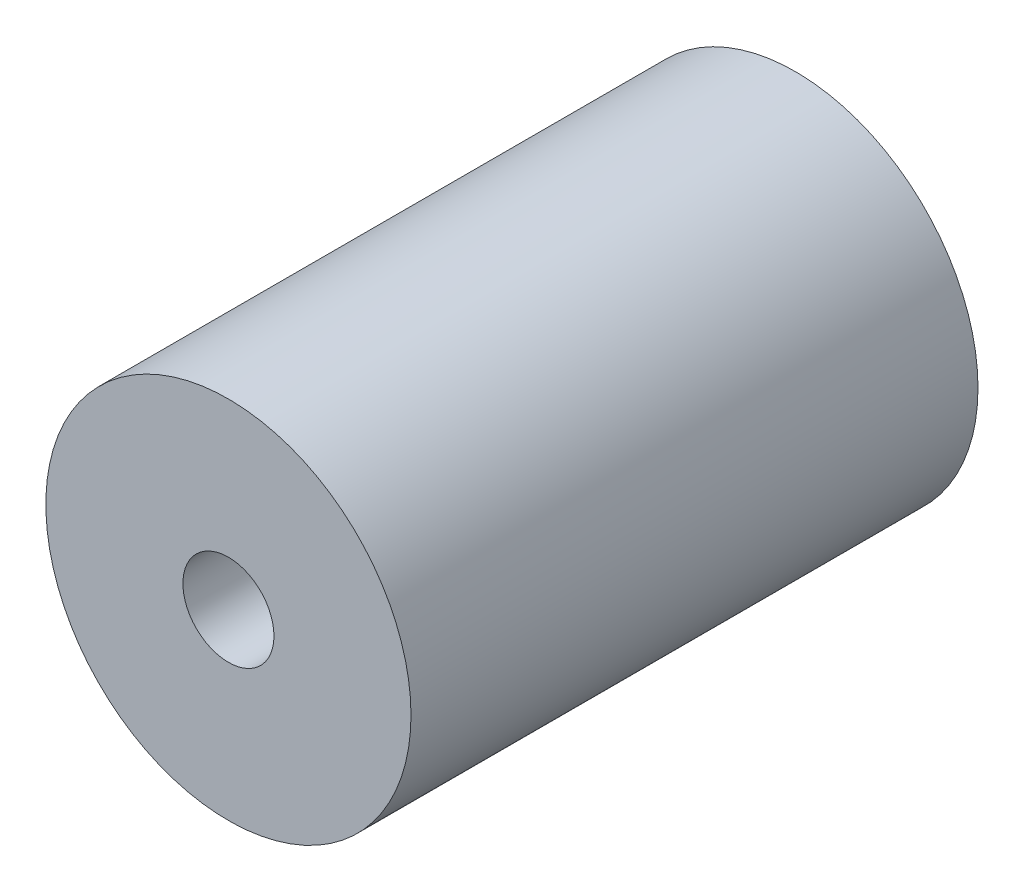
from build123d import *

# Parameters (mm, degrees)
SKETCH1_R                   = 6.1341
BOSS_EXTRUDE1_DEPTH         = 19.05
SKETCH2_R                   = 1.53
CUT_EXTRUDE1_DEPTH          = 20.05
F_1_4_20_TAPPED_HOLE1_D     = 5.1054
F_1_4_20_TAPPED_HOLE1_DEPTH = 9.525
F_1_4_20_TAPPED_HOLE1_TIP   = 1.533816902


with BuildPart() as part:
    # Sketch1 → Boss-Extrude1 (new body)
    with BuildSketch(Plane.XY):
        Circle(SKETCH1_R)
    extrude(amount=BOSS_EXTRUDE1_DEPTH)

    # Sketch2 → Cut-Extrude1 (cut, through all)
    with BuildSketch(Plane.XY.offset(19.05)):
        Circle(SKETCH2_R)
    extrude(amount=-CUT_EXTRUDE1_DEPTH, mode=Mode.SUBTRACT)

    # 1/4-20 Tapped Hole1
    with Locations(Plane(origin=(0, 0, 0), x_dir=(-1, 0, 0), z_dir=(0, 0, -1))):
        with Locations((0, 0)):
            Hole(F_1_4_20_TAPPED_HOLE1_D / 2, depth=F_1_4_20_TAPPED_HOLE1_DEPTH)
            with Locations((0, 0, -(F_1_4_20_TAPPED_HOLE1_DEPTH + F_1_4_20_TAPPED_HOLE1_TIP / 2))):  # 118° drill point
                Cone(0, F_1_4_20_TAPPED_HOLE1_D / 2, F_1_4_20_TAPPED_HOLE1_TIP, mode=Mode.SUBTRACT)


solid = part.part
